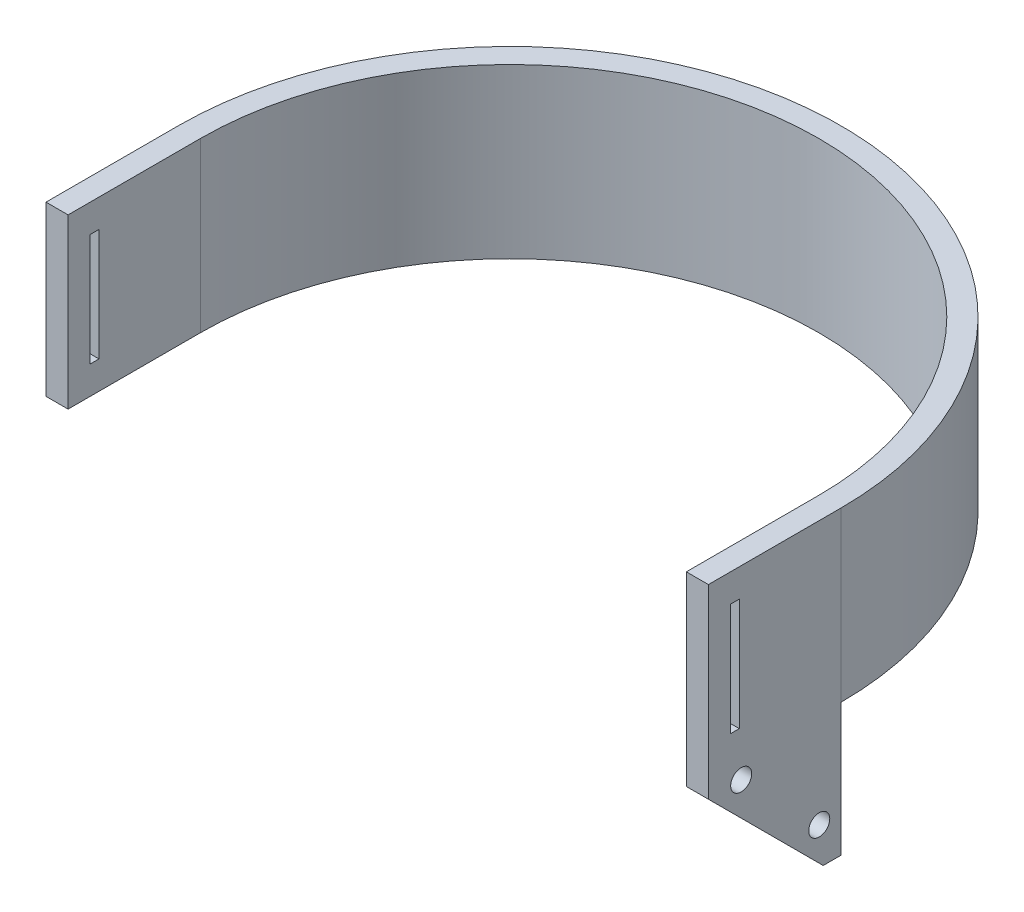
from build123d import *

# Parameters (mm, degrees)
SKETCH1_W           = 5
SKETCH1_H           = 30
BOSS_EXTRUDE1_DEPTH = 38.1
SKETCH2_W           = 2
SKETCH2_H           = 25.4
CUT_EXTRUDE1_DEPTH  = 151
BOSS_EXTRUDE2_DEPTH = 5


with BuildPart() as part:
    # Sketch1 → Boss-Extrude1 (new body)
    with BuildSketch(Plane(origin=(0, 0, 0), x_dir=(1, 0, 0), z_dir=(0, 1, 0))):
        with Locations((-72.5, -15)):
            Rectangle(SKETCH1_W, SKETCH1_H)
        with BuildLine():
            ThreePointArc((75, 0), (0, 75), (-75, 0))
            Line((-75, 0), (-70, 0))
            ThreePointArc((-70, 0), (0, 70), (70, 0))
            Line((70, 0), (75, 0))
        make_face()
        with Locations((72.5, -15)):
            Rectangle(SKETCH1_W, SKETCH1_H)
    extrude(amount=BOSS_EXTRUDE1_DEPTH)

    # Sketch2 → Cut-Extrude1 (cut, through all)
    with BuildSketch(Plane(origin=(75, 0, 0), x_dir=(0, 0, -1), z_dir=(1, 0, 0))):
        with Locations((-24, 19.05)):
            Rectangle(SKETCH2_W, SKETCH2_H)
    extrude(amount=-CUT_EXTRUDE1_DEPTH, mode=Mode.SUBTRACT)

    # Sketch3 → Boss-Extrude2 (add)
    with BuildSketch(Plane(origin=(75, 0, 0), x_dir=(0, 0, -1), z_dir=(1, 0, 0))):
        Polygon((0, -30), (-30, 0), (-30, -4), (-4, -30), align=None)
        with BuildLine():
            Line((-26.464466094, 0), (-30, 0))
            Line((-30, 0), (0, -30))
            Line((0, -30), (0, -26.464466094))
            Line((0, -26.464466094), (-3.213911245, -23.250554849))
            ThreePointArc((-3.213911245, -23.250554849), (-6.581507291, -23.250554849), (-6.581507291, -19.882958803))
            Line((-6.581507291, -19.882958803), (-20.891580775, -5.572885319))
            ThreePointArc((-20.891580775, -5.572885319), (-24.25917682, -5.572885319), (-24.25917682, -2.205289274))
            Line((-24.25917682, -2.205289274), (-26.464466094, 0))
        make_face()
        with BuildLine():
            Line((-22.928932188, 0), (-26.464466094, 0))
            Line((-26.464466094, 0), (-24.25917682, -2.205289274))
            ThreePointArc((-24.25917682, -2.205289274), (-21.664113874, -1.68909916), (-20.194128798, -3.889087297))
            ThreePointArc((-20.194128798, -3.889087297), (-20.375390661, -4.80035222), (-20.891580775, -5.572885319))
            Line((-20.891580775, -5.572885319), (-6.581507291, -19.882958803))
            ThreePointArc((-6.581507291, -19.882958803), (-3.986444345, -19.366768689), (-2.516459268, -21.566756826))
            ThreePointArc((-2.516459268, -21.566756826), (-2.697721131, -22.47802175), (-3.213911245, -23.250554849))
            Line((-3.213911245, -23.250554849), (0, -26.464466094))
            Line((0, -26.464466094), (0, -22.928932188))
            Line((0, -22.928932188), (-22.928932188, 0))
        make_face()
        Polygon((0, 0), (-22.928932188, 0), (0, -22.928932188), align=None)
    extrude(amount=-BOSS_EXTRUDE2_DEPTH)


solid = part.part
